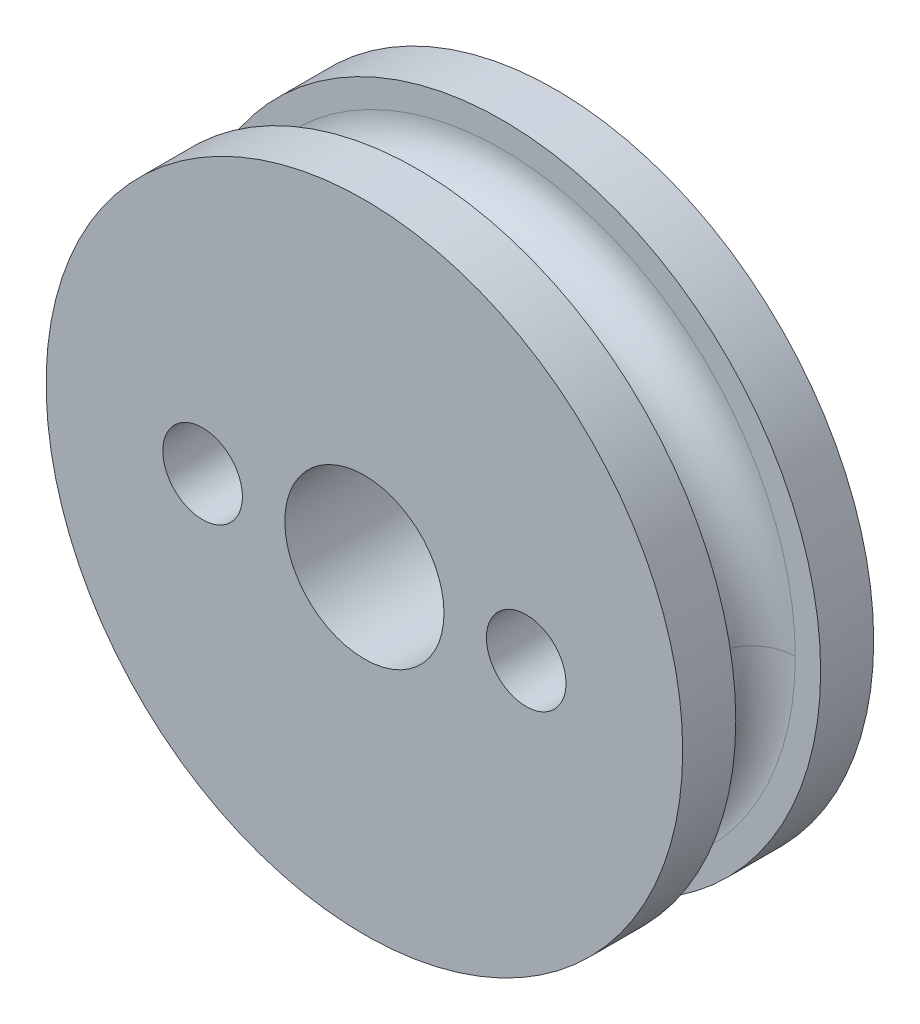
from build123d import *

# Parameters (mm, degrees)
SKETCH_1_R          = 12
EXTRUDE_1_DEPTH     = 2
SKETCH_2_R          = 11
EXTRUDE_2_DEPTH     = 3.2
SKETCH_3_R          = 12
EXTRUDE_3_DEPTH     = 2
SKETCH_4_R          = 3
CUT_EXTRUDE_1_DEPTH = 30
SKETCH_5_R          = 1.5
CUT_EXTRUDE_4_DEPTH = 19.434749795
SKETCH_3D_2_R       = 1.600287212
SKETCH_7_R          = 3
CUT_EXTRUDE_9_DEPTH = 4


with BuildPart() as part:
    # ｽｹｯﾁ1 → ﾎﾞｽ - 押し出し1 (new body)
    with BuildSketch(Plane.XY):
        Circle(SKETCH_1_R)
    extrude(amount=EXTRUDE_1_DEPTH)

    # ｽｹｯﾁ2 → ﾎﾞｽ - 押し出し2 (add)
    with BuildSketch(Plane.XY.offset(2)):
        Circle(SKETCH_2_R)
    extrude(amount=EXTRUDE_2_DEPTH)

    # ｽｹｯﾁ3 → ﾎﾞｽ - 押し出し3 (add)
    with BuildSketch(Plane.XY.offset(5.2)):
        Circle(SKETCH_3_R)
    extrude(amount=EXTRUDE_3_DEPTH)

    # ｽｹｯﾁ4 → ｶｯﾄ - 押し出し1 (cut)
    with BuildSketch(Plane(origin=(0, 0, 0), x_dir=(-1, 0, 0), z_dir=(0, 0, -1))):
        Circle(SKETCH_4_R)
    extrude(amount=-CUT_EXTRUDE_1_DEPTH, mode=Mode.SUBTRACT)

    # ｽｹｯﾁ5 → ｶｯﾄ - 押し出し4 (cut, through all)
    with BuildSketch(Plane(origin=(0, 0, 0), x_dir=(-1, 0, 0), z_dir=(0, 0, -1))):
        with Locations((-6.1, 0)):
            Circle(SKETCH_5_R)
        with Locations((6.1, 0)):
            Circle(SKETCH_5_R)
    extrude(amount=-CUT_EXTRUDE_4_DEPTH, mode=Mode.SUBTRACT)

    # ｶｯﾄ - ｽｲｰﾌﾟ2: sweep along a curve in space
    with BuildLine() as sweep_2_path:
        ThreePointArc((11, 0, 5.2), (7.778174593, 7.778174593, 5.2), (0, 11, 5.2))
        ThreePointArc((0, 11, 5.2), (-7.778174593, 7.778174593, 5.2), (-11, 0, 5.2))
        ThreePointArc((-11, 0, 5.2), (-7.778174593, -7.778174593, 5.2), (0, -11, 5.2))
        ThreePointArc((0, -11, 5.2), (7.778174593, -7.778174593, 5.2), (11, 0, 5.2))
    # Sketch 3D_2 → ｶｯﾄ - ｽｲｰﾌﾟ2 (sweep, cut)
    with BuildSketch(Plane(origin=(-11, 0, 5.2), x_dir=(0, 0, -1), z_dir=(0, -1, 0))):
        with Locations((1.600287212, 0)):
            Circle(SKETCH_3D_2_R)
    sweep(path=sweep_2_path.line, mode=Mode.SUBTRACT)

    # ｽｹｯﾁ7 → ｶｯﾄ - 押し出し9 (cut)
    with BuildSketch(Plane(origin=(0, 0, 0), x_dir=(-1, 0, 0), z_dir=(0, 0, -1))):
        with Locations((-6.1, 0)):
            Circle(SKETCH_7_R)
        with Locations((6.1, 0)):
            Circle(SKETCH_7_R)
    extrude(amount=-CUT_EXTRUDE_9_DEPTH, mode=Mode.SUBTRACT)


solid = part.part
